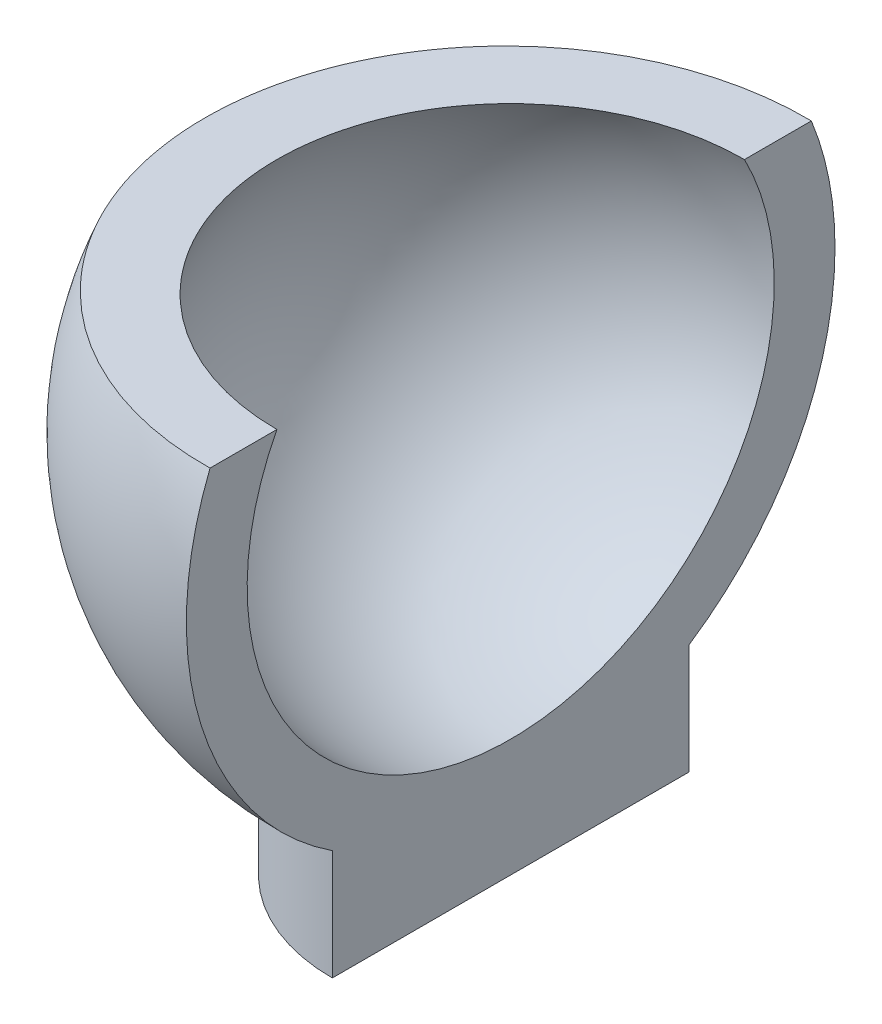
from build123d import *

# Parameters (mm, degrees)
SKETCH2_W           = 42
SKETCH2_H           = 42
CUT_EXTRUDE1_DEPTH  = 20
SKETCH4_R           = 11
BOSS_EXTRUDE1_DEPTH = 3.5
SKETCH5_W           = 37.942079283
SKETCH5_H           = 42.029174216
CUT_EXTRUDE2_DEPTH  = 40


with BuildPart() as part:
    # Sketch1 → Revolve2 (revolve)
    with BuildSketch(Plane(origin=(0, 0, 0), x_dir=(1, 0, 0), z_dir=(0, 1, 0))):
        with BuildLine():
            Line((-20.31846942, 0), (19.68153058, 0))
            ThreePointArc((19.68153058, 0), (-0.31846942, 20), (-20.31846942, 0))
        make_face()
    revolve(axis=Axis((-66.656056584, 0, 0), (1, 0, 0)))

    # Sketch2 → Cut-Extrude1 (cut)
    with BuildSketch(Plane(origin=(0, 7.5, 0), x_dir=(1, 0, 0), z_dir=(0, 1, 0))):
        Rectangle(SKETCH2_W, SKETCH2_H)
    extrude(amount=CUT_EXTRUDE1_DEPTH, mode=Mode.SUBTRACT)

    # Sketch3 → Cut-Revolve1 (revolve, cut)
    with BuildSketch(Plane.XY):
        with BuildLine():
            Line((16.25, 0), (-16.25, 0))
            ThreePointArc((-16.25, 0), (0, -16.25), (16.25, 0))
        make_face()
    revolve(axis=Axis((-20.31846942, 0, 0), (1, 0, 0)), mode=Mode.SUBTRACT)

    # Sketch4 → Boss-Extrude1 (add, symmetric)
    with BuildSketch(Plane(origin=(0, -20, 0), x_dir=(1, 0, 0), z_dir=(0, 1, 0))):
        Circle(SKETCH4_R)
    extrude(amount=BOSS_EXTRUDE1_DEPTH, both=True)

    # Sketch5 → Cut-Extrude2 (cut)
    with BuildSketch(Plane.XZ.offset(23.5)):
        with Locations((18.971039642, 0)):
            Rectangle(SKETCH5_W, SKETCH5_H)
    extrude(amount=-CUT_EXTRUDE2_DEPTH, mode=Mode.SUBTRACT)


solid = part.part
